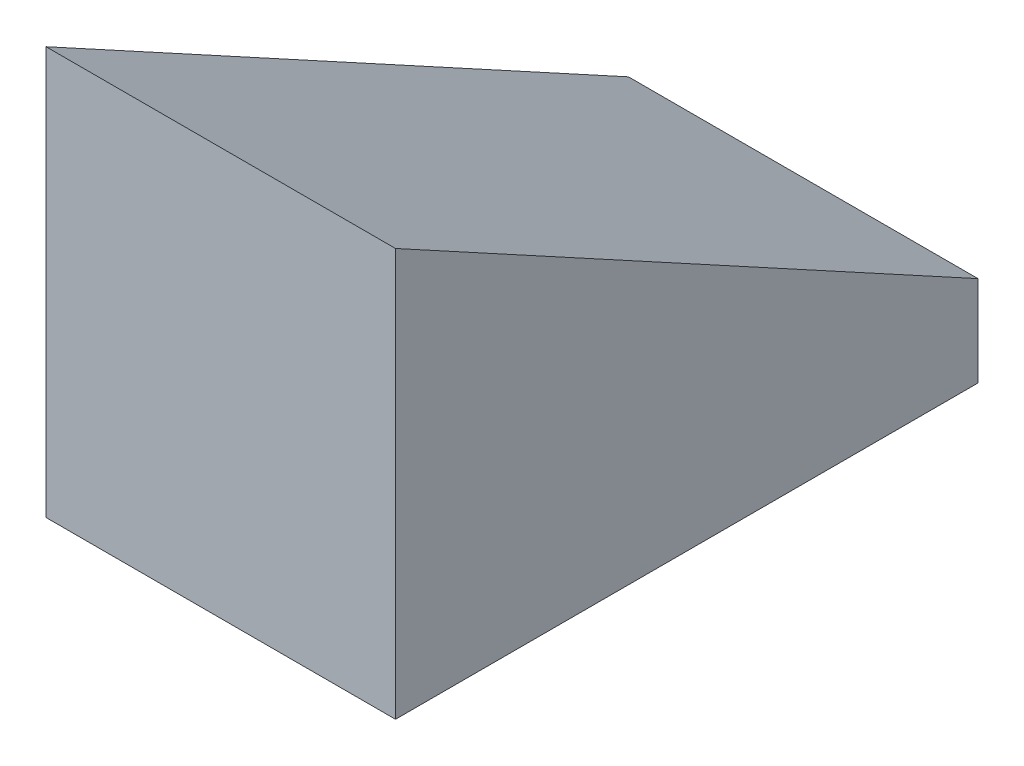
from build123d import *

# Parameters (mm, degrees)
BOSS_EXTRUDE1_DEPTH = 60


with BuildPart() as part:
    # Sketch1 → Boss-Extrude1 (new body)
    with BuildSketch(Plane(origin=(0, 0, 0), x_dir=(0, 0, -1), z_dir=(1, 0, 0))):
        Polygon((0, 0), (0, 70), (100, 15.519322085), (100, 0), align=None)
    extrude(amount=BOSS_EXTRUDE1_DEPTH)


solid = part.part
